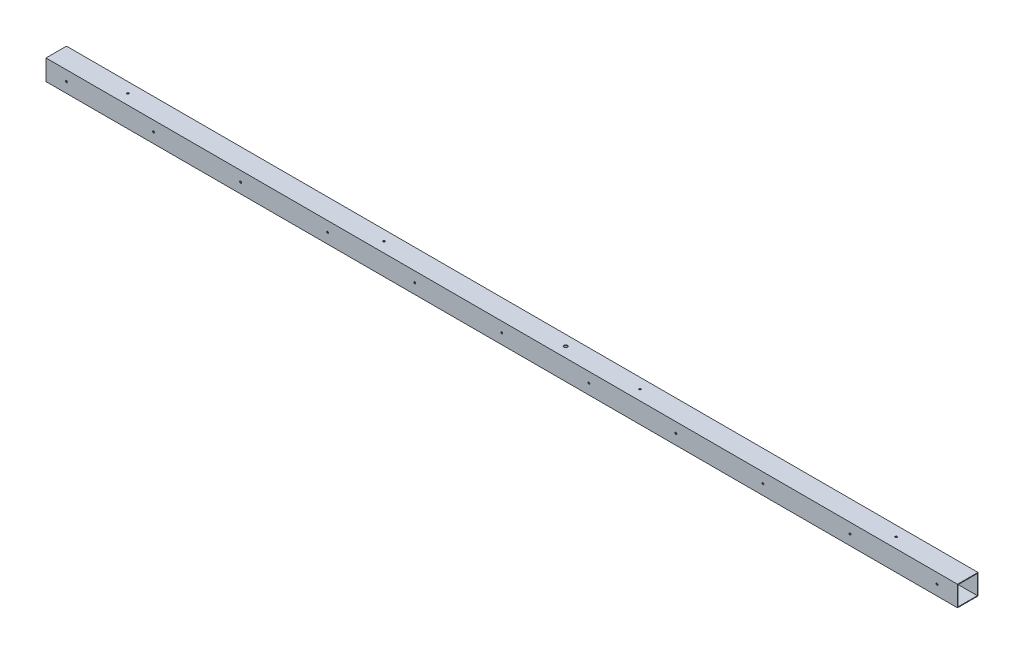
from build123d import *

# Parameters (mm, degrees)
SKETCH1_W           = 50.8
SKETCH1_H           = 50.8
SKETCH1_W_2         = 47.625
SKETCH1_H_2         = 47.625
BOSS_EXTRUDE1_DEPTH = 2260.6
SKETCH3_R           = 2.38125
CUT_EXTRUDE2_DEPTH  = 51.8
LPATTERN2_COUNT     = 11
LPATTERN2_PITCH     = 215.9
SKETCH4_R           = 2.38125
CUT_EXTRUDE3_DEPTH  = 50.8
LPATTERN3_COUNT     = 4
LPATTERN3_PITCH     = 635
SKETCH5_R           = 4.445
CUT_EXTRUDE4_DEPTH  = 51.8


with BuildPart() as part:
    # Sketch1 → Boss-Extrude1 (new body)
    with BuildSketch(Plane(origin=(0, 0, 0), x_dir=(0, 0, -1), z_dir=(1, 0, 0))):
        with Locations((25.4, 25.4)):
            Rectangle(SKETCH1_W, SKETCH1_H)
        with Locations((25.4, 25.4)):
            Rectangle(SKETCH1_W_2, SKETCH1_H_2, mode=Mode.SUBTRACT)
    extrude(amount=BOSS_EXTRUDE1_DEPTH)

    # Sketch3 → Cut-Extrude2 (cut, through all)
    with BuildSketch(Plane(origin=(0, 0, -50.8), x_dir=(-1, 0, 0), z_dir=(0, 0, -1))):
        with Locations((-50.8, 25.4)):
            Circle(SKETCH3_R)
    cut_extrude2 = extrude(amount=-CUT_EXTRUDE2_DEPTH, mode=Mode.SUBTRACT)

    # LPattern2: Cut-Extrude2 ×11
    with Locations(*[(i * LPATTERN2_PITCH, 0, 0) for i in range(1, LPATTERN2_COUNT)]):
        add(cut_extrude2, mode=Mode.SUBTRACT)

    # Sketch4 → Cut-Extrude3 (cut)
    with BuildSketch(Plane.XZ):
        with Locations((177.8, -25.4)):
            Circle(SKETCH4_R)
    cut_extrude3 = extrude(amount=-CUT_EXTRUDE3_DEPTH, mode=Mode.SUBTRACT)

    # LPattern3: Cut-Extrude3 ×4
    with Locations(*[(i * LPATTERN3_PITCH, 0, 0) for i in range(1, LPATTERN3_COUNT)]):
        add(cut_extrude3, mode=Mode.SUBTRACT)

    # Sketch5 → Cut-Extrude4 (cut, through all)
    with BuildSketch(Plane.XZ):
        with Locations((1263.65, -25.4)):
            Circle(SKETCH5_R)
    extrude(amount=-CUT_EXTRUDE4_DEPTH, mode=Mode.SUBTRACT)


solid = part.part
